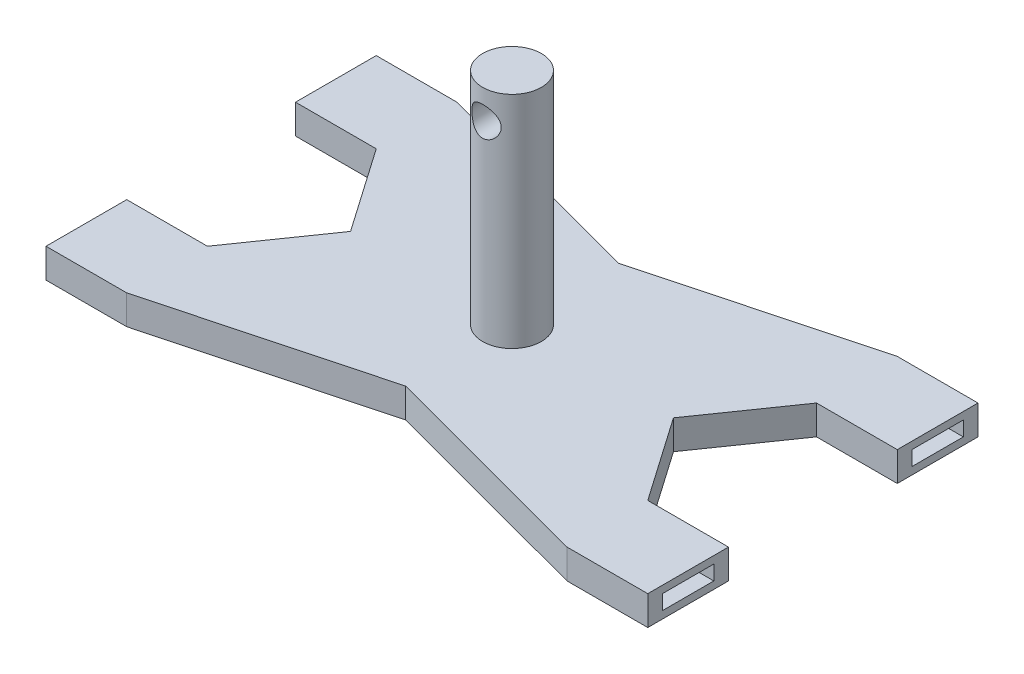
from build123d import *

# Parameters (mm, degrees)
SALIENTE_EXTRUIR1_DEPTH    = 4
CROQUIS4_W                 = 7
CROQUIS4_H                 = 2
CORTAR_EXTRUIR2_DEPTH      = 9
CROQUIS6_W                 = 7
CROQUIS6_H                 = 2
CORTAR_EXTRUIR6_DEPTH      = 9
CROQUIS7_W                 = 7
CROQUIS7_H                 = 2
CORTAR_EXTRUIR4_DEPTH      = 9
CROQUIS8_W                 = 7
CROQUIS8_H                 = 2
CORTAR_EXTRUIR5_DEPTH      = 9
CROQUIS9_R                 = 4
SALIENTE_EXTRUIR2_DEPTH    = 30
CROQUIS10_R                = 2
CORTAR_EXTRUIR7_DEPTH      = 23.5
CORTAR_EXTRUIR7_DEPTH_BACK = 23.5


with BuildPart() as part:
    # Croquis1 → Saliente-Extruir1 (new body)
    with BuildSketch(Plane(origin=(0, 0, 0), x_dir=(1, 0, 0), z_dir=(0, 1, 0))):
        Polygon((-41, -22.5), (-30, -22.5), (0, -14.5), (30, -22.5), (41, -22.5), (41, -11.5), (30, -11.5), (22, 0), (30, 11.5), (41, 11.5), (41, 22.5), (30, 22.5), (0, 14.5), (-30, 22.5), (-41, 22.5), (-41, 11.5), (-30, 11.5), (-22, 0), (-30, -11.5), (-41, -11.5), align=None)
    extrude(amount=SALIENTE_EXTRUIR1_DEPTH)

    # Croquis4 → Cortar-Extruir2 (cut)
    with BuildSketch(Plane.ZY.offset(41)):
        with Locations((-17, 2)):
            Rectangle(CROQUIS4_W, CROQUIS4_H)
    extrude(amount=-CORTAR_EXTRUIR2_DEPTH, mode=Mode.SUBTRACT)

    # Croquis6 → Cortar-Extruir6 (cut)
    with BuildSketch(Plane.ZY.offset(41)):
        with Locations((17, 2)):
            Rectangle(CROQUIS6_W, CROQUIS6_H)
    extrude(amount=-CORTAR_EXTRUIR6_DEPTH, mode=Mode.SUBTRACT)

    # Croquis7 → Cortar-Extruir4 (cut)
    with BuildSketch(Plane(origin=(41, 0, 0), x_dir=(0, 0, -1), z_dir=(1, 0, 0))):
        with Locations((-17, 2)):
            Rectangle(CROQUIS7_W, CROQUIS7_H)
    extrude(amount=-CORTAR_EXTRUIR4_DEPTH, mode=Mode.SUBTRACT)

    # Croquis8 → Cortar-Extruir5 (cut)
    with BuildSketch(Plane(origin=(41, 0, 0), x_dir=(0, 0, -1), z_dir=(1, 0, 0))):
        with Locations((17, 2)):
            Rectangle(CROQUIS8_W, CROQUIS8_H)
    extrude(amount=-CORTAR_EXTRUIR5_DEPTH, mode=Mode.SUBTRACT)

    # Croquis9 → Saliente-Extruir2 (add)
    with BuildSketch(Plane(origin=(0, 4, 0), x_dir=(1, 0, 0), z_dir=(0, 1, 0))):
        Circle(CROQUIS9_R)
    extrude(amount=SALIENTE_EXTRUIR2_DEPTH)

    # Croquis10 → Cortar-Extruir7 (cut, two sides)
    with BuildSketch(Plane.XY) as cortar_extruir7_sk:
        with Locations((0, 30)):
            Circle(CROQUIS10_R)
    extrude(amount=CORTAR_EXTRUIR7_DEPTH, mode=Mode.SUBTRACT)
    extrude(cortar_extruir7_sk.sketch, amount=-CORTAR_EXTRUIR7_DEPTH_BACK, mode=Mode.SUBTRACT)


solid = part.part
